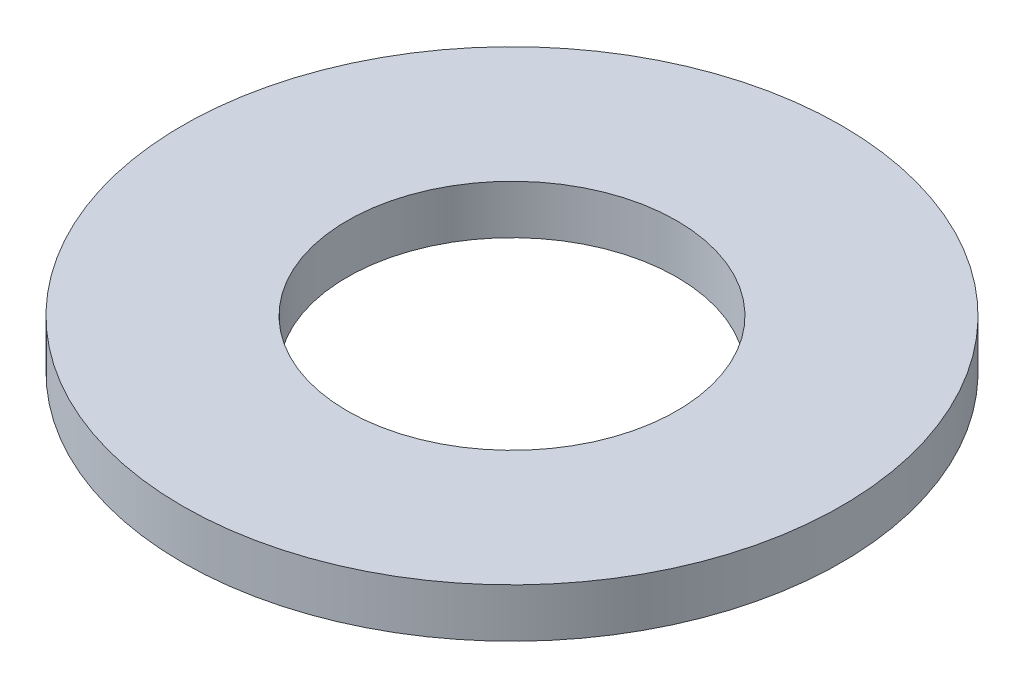
from build123d import *

# Parameters (mm, degrees)
SKETCH3_R                = 8.7376
SKETCH3_R_2              = 4.3688
BOSS_EXTRUDE1_DEPTH      = 0.6477
BOSS_EXTRUDE1_DEPTH_BACK = 0.6477


with BuildPart() as part:
    # Sketch3 → Boss-Extrude1 (new body, two sides)
    with BuildSketch(Plane(origin=(0, 0, 0), x_dir=(1, 0, 0), z_dir=(0, 1, 0))) as boss_extrude1_sk:
        Circle(SKETCH3_R)
        Circle(SKETCH3_R_2, mode=Mode.SUBTRACT)
    extrude(amount=BOSS_EXTRUDE1_DEPTH)
    extrude(boss_extrude1_sk.sketch, amount=-BOSS_EXTRUDE1_DEPTH_BACK)


solid = part.part
